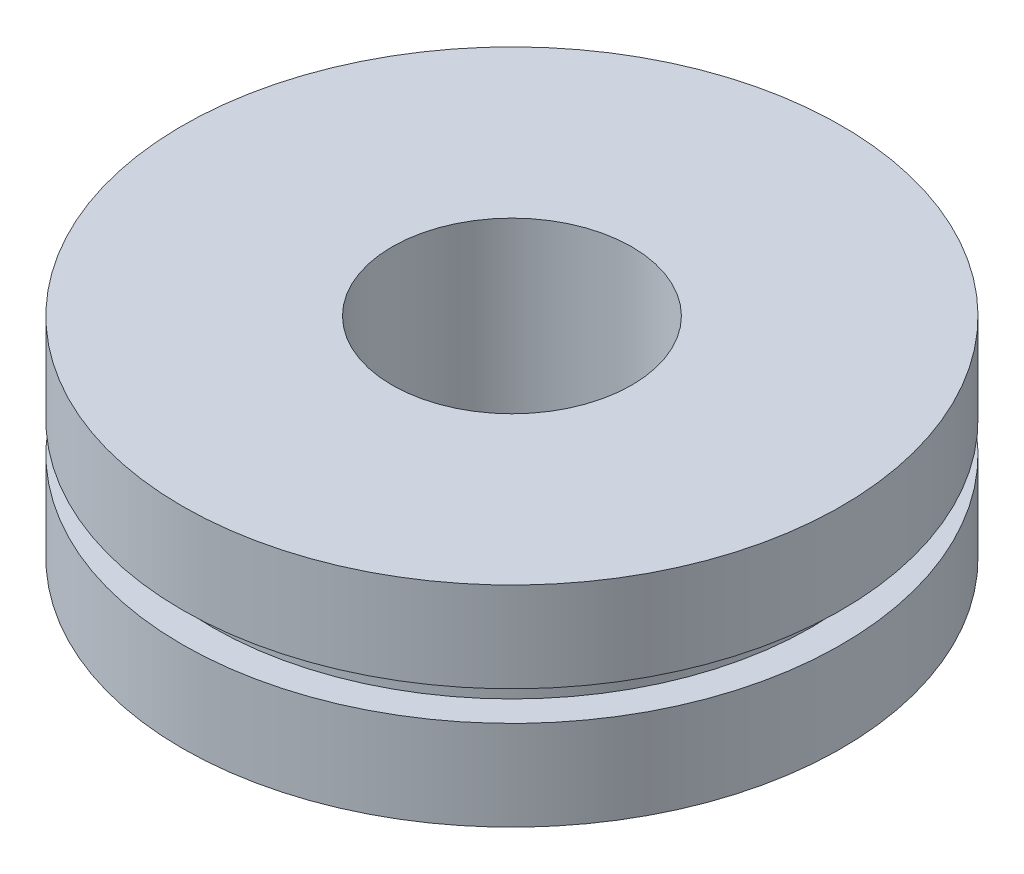
from build123d import *

# Parameters (mm, degrees)
SKETCH_1_R               = 11
SKETCH_1_R_2             = 4
EXTRUDE_1_DEPTH          = 7
SKETCH_2_R               = 12
SKETCH_2_R_2             = 10
CUT_EXTRUDE_1_DEPTH      = 0.5
CUT_EXTRUDE_1_DEPTH_BACK = 0.5


with BuildPart() as part:
    # 草图1 → 凸台-拉伸1 (new body)
    with BuildSketch(Plane(origin=(0, 0, 0), x_dir=(1, 0, 0), z_dir=(0, 1, 0))):
        Circle(SKETCH_1_R)
        Circle(SKETCH_1_R_2, mode=Mode.SUBTRACT)
    extrude(amount=EXTRUDE_1_DEPTH)

    # 草图2 → 切除-拉伸1 (cut, two sides)
    with BuildSketch(Plane(origin=(0, 3.5, 0), x_dir=(1, 0, 0), z_dir=(0, 1, 0))) as cut_extrude_1_sk:
        Circle(SKETCH_2_R)
        Circle(SKETCH_2_R_2, mode=Mode.SUBTRACT)
    extrude(amount=CUT_EXTRUDE_1_DEPTH, mode=Mode.SUBTRACT)
    extrude(cut_extrude_1_sk.sketch, amount=-CUT_EXTRUDE_1_DEPTH_BACK, mode=Mode.SUBTRACT)


solid = part.part
